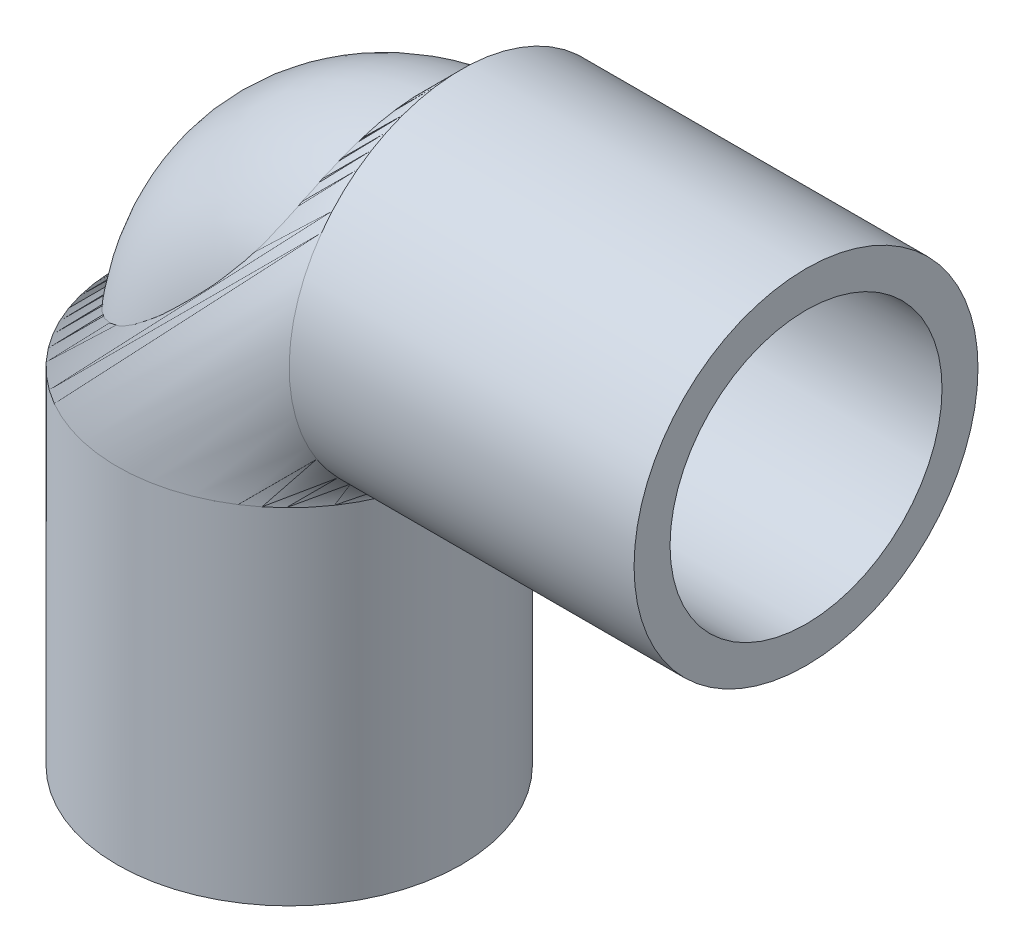
from build123d import *

# Parameters (mm, degrees)
SKETCH1_R   = 16.637
SKETCH1_R_2 = 13.1572


with BuildPart() as part:
    # Sweep4: sweep along a path in Sketch4
    with BuildLine(Plane.XY) as sweep4_path:
        Line((0, 0), (0, 33.363))
        ThreePointArc((0, 33.363), (4.872864481, 45.127135519), (16.637, 50))
        Line((16.637, 50), (50, 50))
    # Sketch1 → Sweep4 (sweep)
    with BuildSketch(Plane(origin=(0, 0, 0), x_dir=(1, 0, 0), z_dir=(0, 1, 0))):
        Circle(SKETCH1_R)
        Circle(SKETCH1_R_2, mode=Mode.SUBTRACT)
    sweep(path=sweep4_path.line)


solid = part.part
